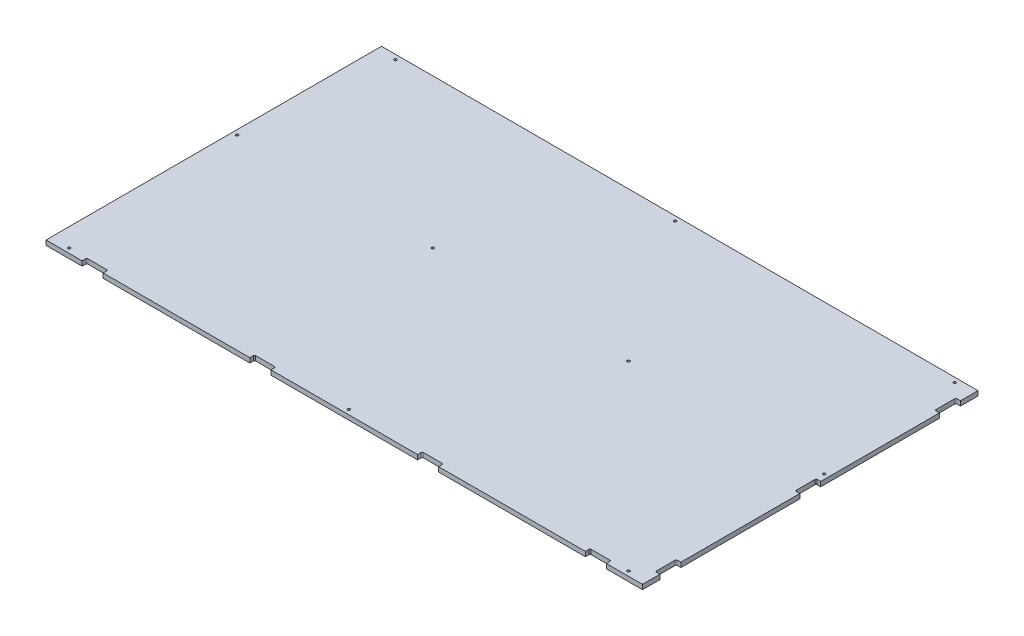
from build123d import *

# Parameters (mm, degrees)
SKETCH1_W                                           = 1625.6
SKETCH1_H                                           = 914.4
BOSS_EXTRUDE1_DEPTH                                 = 12.7
CSK_FOR_1_4_FLAT_HEAD_MACHINE_SCREW_100_D           = 7.14248
CSK_FOR_1_4_FLAT_HEAD_MACHINE_SCREW_100_CSINK_D     = 13.716
CSK_FOR_1_4_FLAT_HEAD_MACHINE_SCREW_100_CSINK_ANGLE = 100
SKETCH5_W                                           = 57.15
SKETCH5_H                                           = 12.7
CUT_EXTRUDE1_DEPTH                                  = 13.7
LPATTERN1_COUNT                                     = 4
LPATTERN1_PITCH                                     = 457.2
SKETCH6_W                                           = 12.7
SKETCH6_H                                           = 57.15
CUT_EXTRUDE2_DEPTH                                  = 13.7
LPATTERN2_COUNT                                     = 3
LPATTERN2_PITCH                                     = 381
FILLET1_R                                           = 3.175


with BuildPart() as part:
    # Sketch1 → Boss-Extrude1 (new body)
    with BuildSketch(Plane(origin=(0, 0, 0), x_dir=(1, 0, 0), z_dir=(0, 1, 0))):
        with Locations((812.8, 457.2)):
            Rectangle(SKETCH1_W, SKETCH1_H)
    extrude(amount=BOSS_EXTRUDE1_DEPTH)

    # CSK for 1/4 Flat Head Machine Screw (100)1 (through all)
    with Locations(Plane(origin=(0, 0, 0), x_dir=(-1, 0, 0), z_dir=(0, -1, 0))):
        with Locations((-50.8, 12.7), (-12.7, 508), (-50.8, 901.7), (-546.1, 508), (-1079.5, 508), (-812.8, 12.7), (-1574.8, 12.7), (-1574.8, 901.7), (-1612.9, 508), (-812.8, 901.7)):
            CounterSinkHole(CSK_FOR_1_4_FLAT_HEAD_MACHINE_SCREW_100_D / 2, CSK_FOR_1_4_FLAT_HEAD_MACHINE_SCREW_100_CSINK_D / 2, counter_sink_angle=CSK_FOR_1_4_FLAT_HEAD_MACHINE_SCREW_100_CSINK_ANGLE)

    # Sketch5 → Cut-Extrude1 (cut, through all)
    with BuildSketch(Plane(origin=(0, 12.7, 0), x_dir=(1, 0, 0), z_dir=(0, 1, 0))):
        with Locations((127, 6.35)):
            Rectangle(SKETCH5_W, SKETCH5_H)
    cut_extrude1 = extrude(amount=-CUT_EXTRUDE1_DEPTH, mode=Mode.SUBTRACT)

    # LPattern1: Cut-Extrude1 ×4
    with Locations(*[(i * LPATTERN1_PITCH, 0, 0) for i in range(1, LPATTERN1_COUNT)]):
        add(cut_extrude1, mode=Mode.SUBTRACT)

    # Sketch6 → Cut-Extrude2 (cut, through all)
    with BuildSketch(Plane(origin=(0, 12.7, 0), x_dir=(1, 0, 0), z_dir=(0, 1, 0))):
        with Locations((1619.25, 76.2)):
            Rectangle(SKETCH6_W, SKETCH6_H)
    cut_extrude2 = extrude(amount=-CUT_EXTRUDE2_DEPTH, mode=Mode.SUBTRACT)

    # LPattern2: Cut-Extrude2 ×3
    with Locations(*[(0, 0, -i * LPATTERN2_PITCH) for i in range(1, LPATTERN2_COUNT)]):
        add(cut_extrude2, mode=Mode.SUBTRACT)

    # Fillet1
    fillet1_edges = [part.edges().sort_by_distance(p)[0] for p in [
        (555.625, 6.35, -12.7),
        (612.775, 6.35, -12.7),
        (1012.825, 6.35, -12.7),
        (1069.975, 6.35, -12.7),
        (1470.025, 6.35, -12.7),
        (1527.175, 6.35, -12.7),
        (1612.9, 6.35, -47.625),
        (1612.9, 6.35, -104.775),
        (1612.9, 6.35, -428.625),
        (1612.9, 6.35, -485.775),
        (1612.9, 6.35, -809.625),
        (1612.9, 6.35, -866.775),
        (98.425, 6.35, -12.7),
        (155.575, 6.35, -12.7),
    ]]
    fillet(fillet1_edges, radius=FILLET1_R)


solid = part.part
